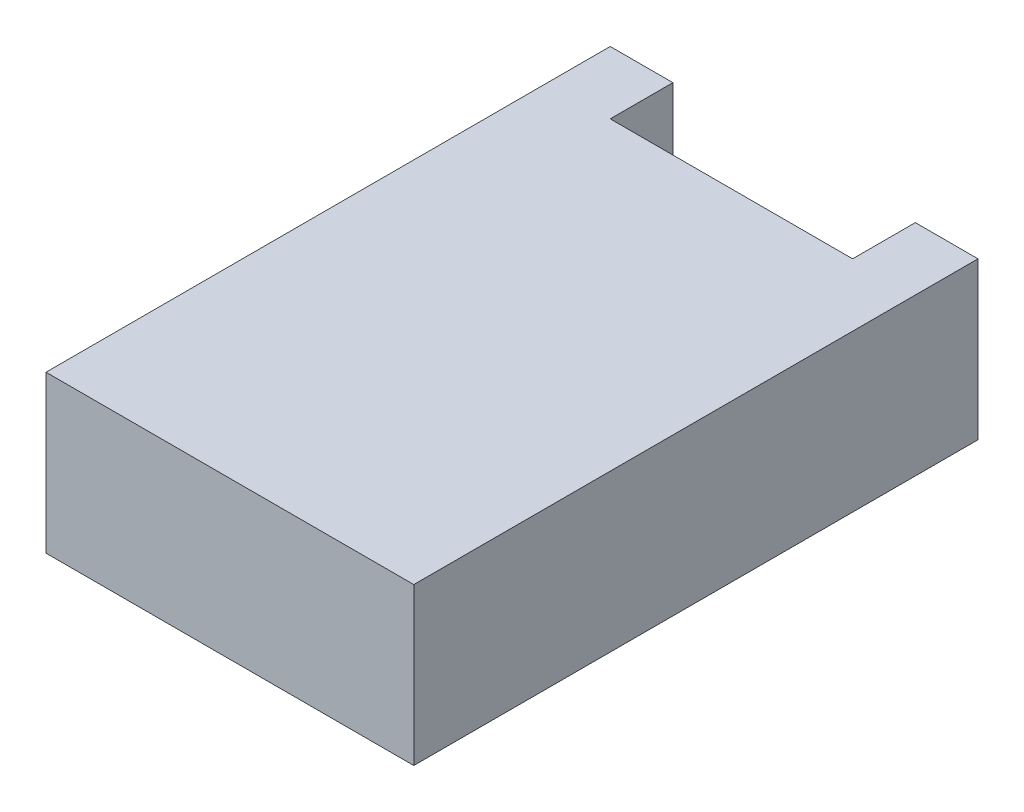
from build123d import *

# Parameters (mm, degrees)
BOSS_EXTRUDE1_DEPTH = 7.5


with BuildPart() as part:
    # Sketch1 → Boss-Extrude1 (new body)
    with BuildSketch(Plane(origin=(0, 0, 0), x_dir=(1, 0, 0), z_dir=(0, 1, 0))):
        Polygon((-8.8, -12), (8.8, -12), (8.8, 12), (8.8, 15), (5.8, 15), (5.8, 12), (-5.8, 12), (-5.8, 15), (-8.8, 15), (-8.8, 12), align=None)
    extrude(amount=BOSS_EXTRUDE1_DEPTH)


solid = part.part
